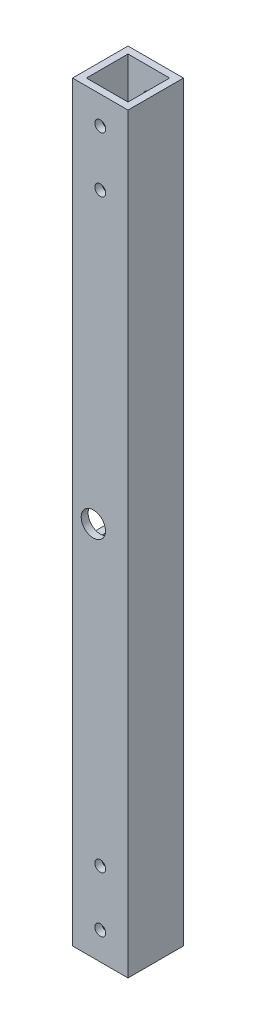
from build123d import *

# Parameters (mm, degrees)
SKETCH1_W           = 25.4
SKETCH1_H           = 25.4
SKETCH1_W_2         = 19.05
SKETCH1_H_2         = 19.05
BOSS_EXTRUDE1_DEPTH = 172.085
SKETCH2_W           = 19.05
SKETCH2_H           = 25.4
CUT_EXTRUDE1_DEPTH  = 3.175
SKETCH3_R           = 2.4892
SKETCH3_R_2         = 5.55625
CUT_EXTRUDE2_DEPTH  = 26.4
FILLET1_R           = 6.35


with BuildPart() as part:
    # Sketch1 → Boss-Extrude1 (new body, symmetric)
    with BuildSketch(Plane(origin=(0, 0, 0), x_dir=(1, 0, 0), z_dir=(0, 1, 0))):
        with Locations((12.7, 0)):
            Rectangle(SKETCH1_W, SKETCH1_H)
        with Locations((12.7, 0)):
            Rectangle(SKETCH1_W_2, SKETCH1_H_2, mode=Mode.SUBTRACT)
    extrude(amount=BOSS_EXTRUDE1_DEPTH, both=True)

    # Sketch2 → Cut-Extrude1 (cut)
    with BuildSketch(Plane.ZY):
        Rectangle(SKETCH2_W, SKETCH2_H)
    extrude(amount=-CUT_EXTRUDE1_DEPTH, mode=Mode.SUBTRACT)

    # Sketch3 → Cut-Extrude2 (cut, through all)
    with BuildSketch(Plane(origin=(0, 0, -12.7), x_dir=(-1, 0, 0), z_dir=(0, 0, -1))):
        with Locations((-12.7, -159.385)):
            Circle(SKETCH3_R)
        with Locations((-12.7, -133.985)):
            Circle(SKETCH3_R)
        with Locations((-9.525, 0)):
            Circle(SKETCH3_R_2)
    cut_extrude2 = extrude(amount=-CUT_EXTRUDE2_DEPTH, mode=Mode.SUBTRACT)

    # Mirror1: Cut-Extrude2 across plane
    add(cut_extrude2.mirror(Plane.ZX), mode=Mode.SUBTRACT)

    # Fillet1
    fillet1_edges = [part.edges().sort_by_distance(p)[0] for p in [
        (1.5875, 12.7, -9.525),
        (1.5875, -12.7, -9.525),
        (1.5875, -12.7, 9.525),
        (1.5875, 12.7, 9.525),
    ]]
    fillet(fillet1_edges, radius=FILLET1_R)


solid = part.part
